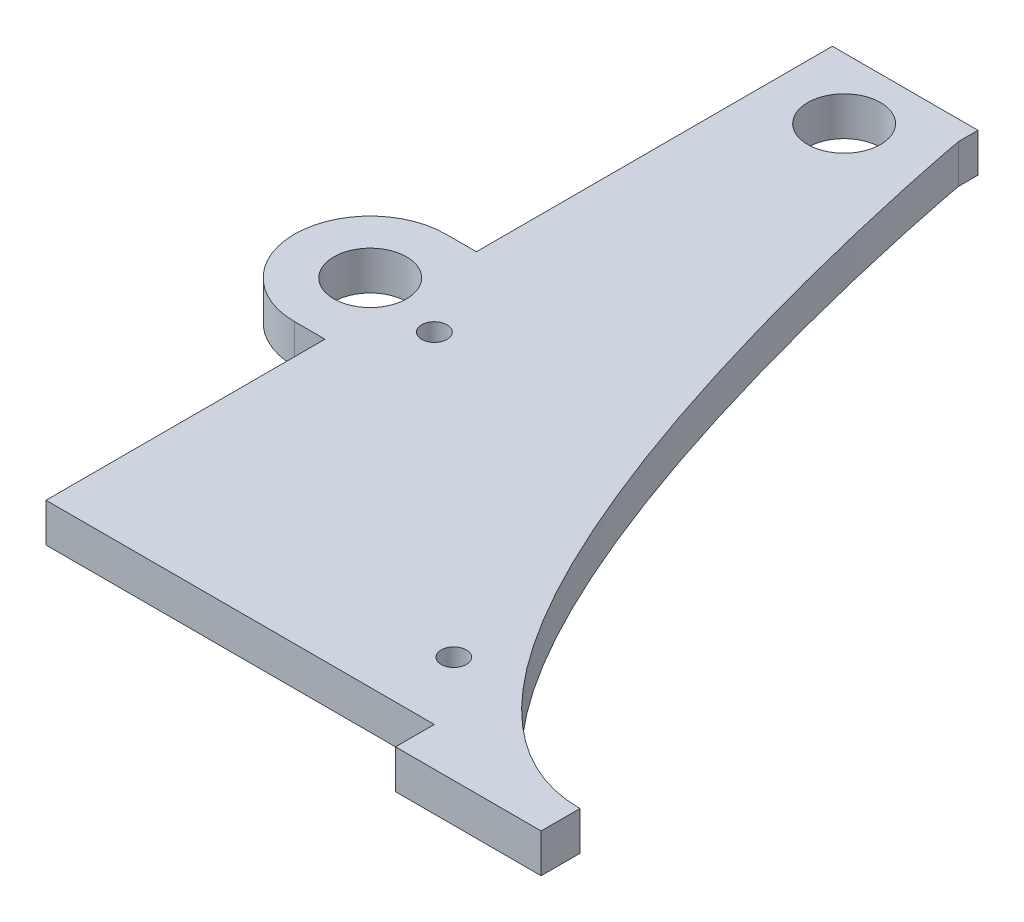
from build123d import *

# Parameters (mm, degrees)
SKETCH1_R               = 4.7625
BOSS_EXTRUDE1_DEPTH     = 5.08
SKETCH4_W               = 19.05
SKETCH4_H               = 5.08
BOSS_EXTRUDE2_DEPTH     = 5.08
SKETCH6_R               = 4.7625
BOSS_EXTRUDE3_DEPTH     = 5.08
SKETCH8_R               = 4.7625
CUT_EXTRUDE2_DEPTH      = 6.0800001
SKETCH5_R               = 1.651
SKETCH5_R_2             = 1.660728382
CUT_EXTRUDE1_DEPTH      = 1.0000001
CUT_EXTRUDE1_DEPTH_BACK = 6.0800001


with BuildPart() as part:
    # Sketch1 → Boss-Extrude1 (new body)
    with BuildSketch(Plane(origin=(0, 0, 0), x_dir=(1, 0, 0), z_dir=(0, 1, 0))):
        with BuildLine():
            Line((-9.525, 53.975), (9.525, 53.975))
            Line((9.525, 53.975), (9.525, 51.435))
            add(Edge.make_bspline(
                [(9.525, 51.435), (9.525, 51.21454564), (27.819109584, -48.895), (60.325, -48.895)],
                knots=[0, 0, 0, 0, 1, 1, 1, 1], degree=3))
            Line((60.325, -48.895), (-9.525, -48.895))
            Line((-9.525, -48.895), (-9.525, 53.975))
        make_face()
        with Locations((0, 45.9867)):
            Circle(SKETCH1_R, mode=Mode.SUBTRACT)
    extrude(amount=BOSS_EXTRUDE1_DEPTH)

    # Sketch4 → Boss-Extrude2 (add)
    with BuildSketch(Plane(origin=(0, 5.08, 0), x_dir=(1, 0, 0), z_dir=(0, 1, 0))):
        with Locations((50.8, -51.435)):
            Rectangle(SKETCH4_W, SKETCH4_H)
    extrude(amount=-BOSS_EXTRUDE2_DEPTH)

    # Sketch6 → Boss-Extrude3 (add)
    with BuildSketch(Plane.XZ):
        with BuildLine():
            Line((-13.5128, 12.403582), (-9.525, 12.403582))
            Line((-9.525, 12.403582), (-9.525, 11.565453148))
            ThreePointArc((-9.525, 11.565453148), (-3.6068, 2.497582), (-9.525, -6.570289148))
            Line((-9.525, -6.570289148), (-9.525, -7.408418))
            Line((-9.525, -7.408418), (-13.5128, -7.408418))
            ThreePointArc((-13.5128, -7.408418), (-23.4188, 2.497582), (-13.5128, 12.403582))
        make_face()
        with Locations((-13.5128, 2.497582)):
            Circle(SKETCH6_R, mode=Mode.SUBTRACT)
    extrude(amount=-BOSS_EXTRUDE3_DEPTH)

    # Sketch8 → Cut-Extrude2 (cut, through all)
    with BuildSketch(Plane(origin=(0, 5.08, 0), x_dir=(1, 0, 0), z_dir=(0, 1, 0))):
        with Locations((-13.5128, -2.497582)):
            Circle(SKETCH8_R)
    extrude(amount=-CUT_EXTRUDE2_DEPTH, mode=Mode.SUBTRACT)

    # Sketch5 → Cut-Extrude1 (cut, two sides)
    with BuildSketch(Plane.XZ) as cut_extrude1_sk:
        with Locations((34.925, 40.005)):
            Circle(SKETCH5_R)
        with Locations((-3.175, 4.445)):
            Circle(SKETCH5_R_2)
    extrude(amount=CUT_EXTRUDE1_DEPTH, mode=Mode.SUBTRACT)
    extrude(cut_extrude1_sk.sketch, amount=-CUT_EXTRUDE1_DEPTH_BACK, mode=Mode.SUBTRACT)


solid = part.part
